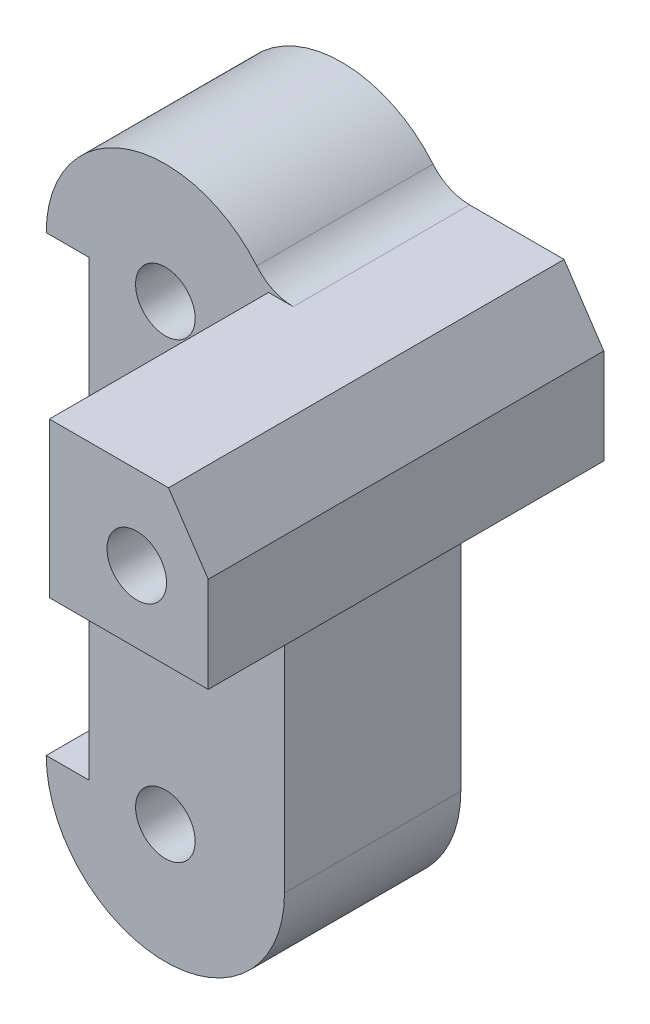
from build123d import *

# Parameters (mm, degrees)
EXTRUDE_1_DEPTH        = 7.4
EXTRUDE_2_DEPTH        = 9.2
HOLE_WIZARD_M3_1_D     = 2.5
HOLE_WIZARD_M3_1_DEPTH = 6.5
HOLE_WIZARD_M3_1_TIP   = 0.751075774
HOLE_WIZARD_M3_3_D     = 2.5
FILLET_1_R             = 2
CUT_EXTRUDE_1_DEPTH    = 5
HOLE_WIZARD_M3_5_D     = 2.5


with BuildPart() as part:
    # 草图1 → 凸台-拉伸1 (new body)
    with BuildSketch(Plane.XY):
        with BuildLine():
            Line((-3.2, 19), (-3.2, 0))
            Line((-3.2, 0), (-5, 0))
            ThreePointArc((-5, 0), (0, -5), (5, 0))
            Line((5, 0), (5, 4))
            Line((5, 4), (5, 15))
            Line((5, 15), (11, 15))
            Line((11, 15), (11, 19))
            Line((11, 19), (9.333333333, 21.494438258))
            Line((9.333333333, 21.494438258), (4.333333333, 21.494438258))
            ThreePointArc((4.333333333, 21.494438258), (-1.290994449, 23.830458915), (-5, 19))
            Line((-5, 19), (-3.2, 19))
        make_face()
    extrude(amount=EXTRUDE_1_DEPTH)

    # 草图2 → 凸台-拉伸2 (add)
    with BuildSketch(Plane.XY.offset(7.4)):
        Polygon((11, 19), (9.333333333, 21.494438258), (4.333333333, 21.494438258), (4.333333333, 15), (5, 15), (11, 15), align=None)
    extrude(amount=EXTRUDE_2_DEPTH)

    # M3 螺纹孔1
    with Locations(Plane(origin=(-3.2, 15, 4.4), x_dir=(0, -1, 0), z_dir=(-1, 0, 0))):
        with Locations((0, 0), (10, 0)):
            Hole(HOLE_WIZARD_M3_1_D / 2, depth=HOLE_WIZARD_M3_1_DEPTH)
            with Locations((0, 0, -(HOLE_WIZARD_M3_1_DEPTH + HOLE_WIZARD_M3_1_TIP / 2))):  # 118° drill point
                Cone(0, HOLE_WIZARD_M3_1_D / 2, HOLE_WIZARD_M3_1_TIP, mode=Mode.SUBTRACT)

    # M3 螺纹孔3 (through all)
    with Locations(Plane.XY.offset(7.4)):
        with Locations((0, 0), (0, 19)):
            Hole(HOLE_WIZARD_M3_3_D / 2)

    # 圆角1
    fillet_1_edges = [part.edges().sort_by_distance(p)[0] for p in [
        (4.333333333, 21.494438258, 3.7),
    ]]
    fillet(fillet_1_edges, radius=FILLET_1_R)

    # 草图10 → 切除-拉伸1 (cut)
    with BuildSketch(Plane(origin=(0, 13.5, 0), x_dir=(1, 0, 0), z_dir=(0, 1, 0))):
        Polygon((-3.2, -7.4), (-0.371572875, -7.4), (-3.2, -4.571572875), align=None)
    extrude(amount=-CUT_EXTRUDE_1_DEPTH, mode=Mode.SUBTRACT)

    # M3 螺纹孔5 (through all)
    with Locations(Plane(origin=(8, 18, 16.6), x_dir=(1, 0, 0), z_dir=(0, 0, 1))):
        with Locations((0, 0)):
            Hole(HOLE_WIZARD_M3_5_D / 2)


solid = part.part
